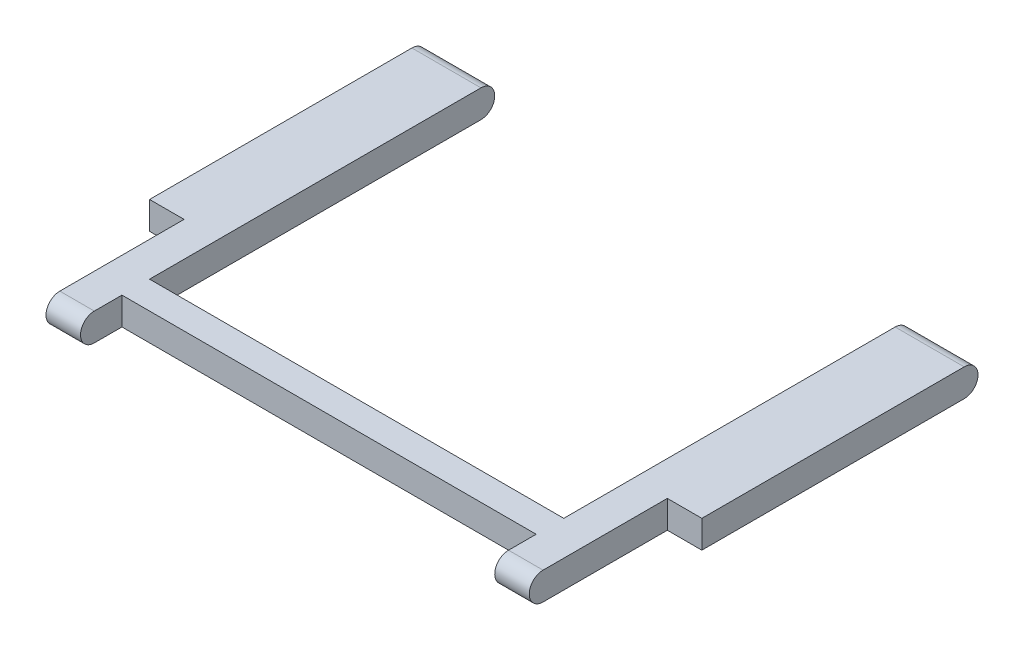
from build123d import *

# Parameters (mm, degrees)
EXTRUDE_1_DEPTH     = 80
SKETCH_3_W          = 60
SKETCH_3_H          = 16.054950693
SKETCH_3_H_2        = 56.960343262
CUT_EXTRUDE_1_DEPTH = 10
SKETCH_4_W          = 5
SKETCH_4_H          = 20
CUT_EXTRUDE_2_DEPTH = 10


with BuildPart() as part:
    # 草图2 → 凸台-拉伸1 (new body)
    with BuildSketch(Plane(origin=(0, 0, 0), x_dir=(0, 0, -1), z_dir=(1, 0, 0))):
        with BuildLine():
            Line((-28, 2), (28, 2))
            ThreePointArc((28, 2), (30, 0), (28, -2))
            Line((28, -2), (-28, -2))
            ThreePointArc((-28, -2), (-30, 0), (-28, 2))
        make_face()
    extrude(amount=EXTRUDE_1_DEPTH)

    # 草图3 → 切除-拉伸1 (cut)
    with BuildSketch(Plane(origin=(0, 2, 0), x_dir=(1, 0, 0), z_dir=(0, 1, 0))):
        with Locations((40, -32.027475346)):
            Rectangle(SKETCH_3_W, SKETCH_3_H)
        with Locations((40, 8.480171631)):
            Rectangle(SKETCH_3_W, SKETCH_3_H_2)
    extrude(amount=-CUT_EXTRUDE_1_DEPTH, mode=Mode.SUBTRACT)

    # 草图4 → 切除-拉伸2 (cut)
    with BuildSketch(Plane(origin=(0, 2, 0), x_dir=(1, 0, 0), z_dir=(0, 1, 0))):
        with Locations((2.5, -20)):
            Rectangle(SKETCH_4_W, SKETCH_4_H)
        with Locations((77.5, -20)):
            Rectangle(SKETCH_4_W, SKETCH_4_H)
    extrude(amount=-CUT_EXTRUDE_2_DEPTH, mode=Mode.SUBTRACT)


solid = part.part
